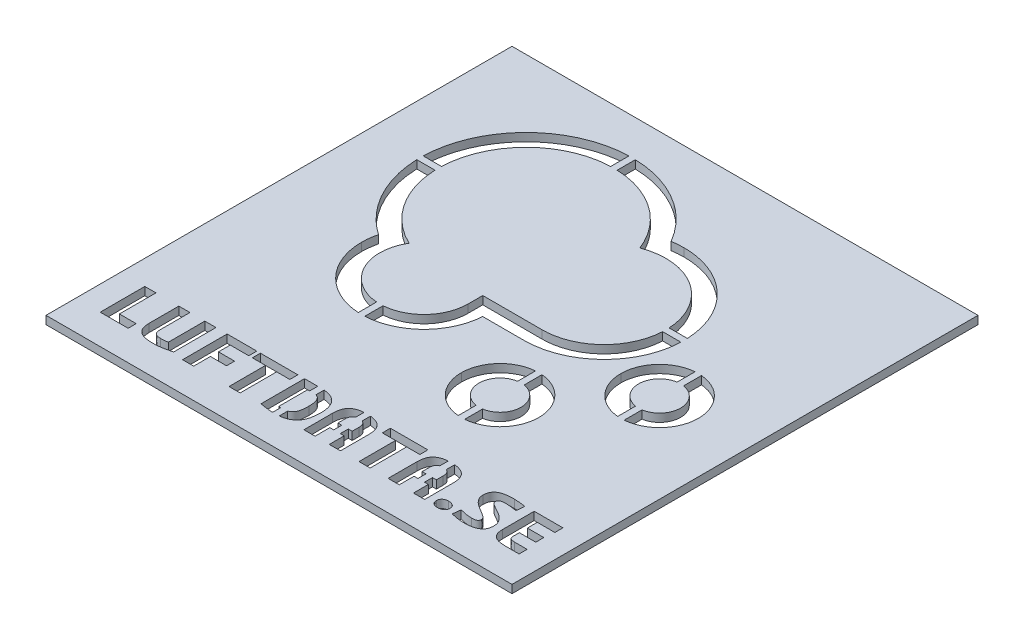
from build123d import *

# Parameters (mm, degrees)
BOSS_EXTRUDE2_DEPTH   = 2
SKETCH4_W             = 115
SKETCH4_H             = 115
BOSS_EXTRUDE2_2_DEPTH = 2
BOSS_EXTRUDE2_3_DEPTH = 2
BOSS_EXTRUDE2_4_DEPTH = 2
CUT_EXTRUDE1_DEPTH    = 2
SKETCH6_W             = 1.6
SKETCH6_H             = 9.016392518
SKETCH6_W_2           = 12.548523478
SKETCH6_H_2           = 1.6
SKETCH6_W_3           = 7.900848197
SKETCH6_H_3           = 10.834577131
SKETCH6_H_4           = 23.73823121
SKETCH6_H_5           = 23.744170643
SKETCH6_H_6           = 4.728687102
SKETCH6_H_7           = 7.537538453
SKETCH6_H_8           = 10.871158563
BOSS_EXTRUDE3_DEPTH   = 2


with BuildPart() as part:
    # Sketch4 → Boss-Extrude2 (new body)
    with BuildSketch(Plane(origin=(0, 0, 0), x_dir=(1, 0, 0), z_dir=(0, 1, 0))):
        with BuildLine():
            Line((-7.842765972, -9.564784729), (-7.842765972, -13.155399048))
            add(Edge.make_bspline(
                [(-7.842765972, -13.155399048), (-7.842935541, -19.185382566), (-12.733091514, -24.0752597), (-18.763092198, -24.075090131)],
                knots=[6, 6, 6, 6, 7, 7, 7, 7], degree=3))
            add(Edge.make_bspline(
                [(-18.763092198, -24.075090131), (-24.793092882, -24.074920559), (-29.682935683, -19.1847684), (-29.682766111, -13.154784881)],
                knots=[7, 7, 7, 7, 8, 8, 8, 8], degree=3))
            add(Edge.make_bspline(
                [(-29.682766111, -13.154784881), (-29.682766111, -11.079765045), (-29.102785261, -9.139766418), (-28.09776512, -7.489764892)],
                knots=[8, 8, 8, 8, 9, 9, 9, 9], degree=3))
            add(Edge.make_bspline(
                [(-28.09776512, -7.489764892), (-35.447785528, -4.019767486), (-40.527766378, 3.460212982), (-40.527766378, 12.125213898)],
                knots=[9, 9, 9, 9, 10, 10, 10, 10], degree=3))
            add(Edge.make_bspline(
                [(-40.527766378, 12.125213898), (-40.527766378, 24.100233353), (-30.81776634, 33.810213364), (-18.837766798, 33.810213364)],
                knots=[10, 10, 10, 10, 11, 11, 11, 11], degree=3))
            add(Edge.make_bspline(
                [(-18.837766798, 33.810213364), (-9.632766874, 33.810213364), (-1.767746122, 28.070232666), (1.377235262, 19.980232514)],
                knots=[0, 0, 0, 0, 1, 1, 1, 1], degree=3))
            add(Edge.make_bspline(
                [(1.377235262, 19.980232514), (3.067233889, 20.625213898), (4.902232973, 20.980232514), (6.822234957, 20.980232514)],
                knots=[1, 1, 1, 1, 2, 2, 2, 2], degree=3))
            add(Edge.make_bspline(
                [(6.822234957, 20.980232514), (15.257232515, 20.980232514), (22.0922316, 14.145214356), (22.0922316, 5.710212982)],
                knots=[2, 2, 2, 2, 3, 3, 3, 3], degree=3))
            add(Edge.make_bspline(
                [(22.0922316, 5.710212982), (22.0922316, -2.724784576), (15.257232515, -9.564784729), (6.822234957, -9.564784729)],
                knots=[3, 3, 3, 3, 4, 4, 4, 4], degree=3))
            Line((6.822234957, -9.564784729), (-7.842765972, -9.564784729))
        make_face()
    extrude(amount=BOSS_EXTRUDE2_DEPTH)



with BuildPart() as body_2:
    # Sketch4 → Boss-Extrude2 2 (new body)
    with BuildSketch(Plane(origin=(0, 0, 0), x_dir=(1, 0, 0), z_dir=(0, 1, 0))):
        with Locations((0, -10.190399849)):
            Rectangle(SKETCH4_W, SKETCH4_H)
        with BuildLine():
            Line((-3.369278118, -14.064975464), (6.822040394, -14.06540271))
            add(Edge.make_bspline(
                [(6.822040394, -14.06540271), (17.723441914, -14.06540271), (26.592231587, -5.194381439), (26.592231587, 5.709598816)],
                knots=[6, 6, 6, 6, 7, 7, 7, 7], degree=3))
            add(Edge.make_bspline(
                [(26.592231587, 5.709598816), (26.592231587, 16.610832489), (17.723441914, 25.479618347), (6.822234944, 25.479618347)],
                knots=[7, 7, 7, 7, 8, 8, 8, 8], degree=3))
            add(Edge.make_bspline(
                [(6.822234944, 25.479618347), (5.811405018, 25.479618347), (4.809924916, 25.403877533), (3.82228835, 25.253231323)],
                knots=[8, 8, 8, 8, 9, 9, 9, 9], degree=3))
            add(Edge.make_bspline(
                [(3.82228835, 25.253231323), (1.910270527, 28.555517471), (-0.706497356, 31.405149735), (-3.884784862, 33.620214737)],
                knots=[9, 9, 9, 9, 10, 10, 10, 10], degree=3))
            add(Edge.make_bspline(
                [(-3.884784862, 33.620214737), (-8.286651775, 36.688041962), (-13.457325145, 38.309600151), (-18.837766811, 38.309600151)],
                knots=[10, 10, 10, 10, 11, 11, 11, 11], degree=3))
            add(Edge.make_bspline(
                [(-18.837766811, 38.309600151), (-33.278976604, 38.309600151), (-45.027765915, 26.563061035), (-45.027765915, 12.124599732)],
                knots=[0, 0, 0, 0, 1, 1, 1, 1], degree=3))
            add(Edge.make_bspline(
                [(-45.027765915, 12.124599732), (-45.027765915, 3.483356751), (-40.700526401, -4.580489838), (-33.724340602, -9.419315063)],
                knots=[1, 1, 1, 1, 2, 2, 2, 2], degree=3))
            add(Edge.make_bspline(
                [(-33.724340602, -9.419315063), (-34.027487918, -10.634566986), (-34.182766124, -11.888732635), (-34.182766124, -13.155399048)],
                knots=[2, 2, 2, 2, 3, 3, 3, 3], degree=3))
            add(Edge.make_bspline(
                [(-34.182766124, -13.155399048), (-34.182766124, -21.65801593), (-27.265400096, -28.575397217), (-18.762785122, -28.575397217)],
                knots=[3, 3, 3, 3, 4, 4, 4, 4], degree=3))
            add(Edge.make_bspline(
                [(-18.762785122, -28.575397217), (-10.565300151, -28.575397217), (-3.841350719, -22.146121704), (-3.369278118, -14.064975464)],
                knots=[4, 4, 4, 4, 5, 5, 5, 5], degree=3))
        make_face(mode=Mode.SUBTRACT)
        with BuildLine():
            add(Edge.make_bspline(
                [(15.583556965, -38.288196289), (20.8599623, -38.288196289), (25.152625874, -33.995532715), (25.152625874, -28.71912738)],
                knots=[2, 2, 2, 2, 3, 3, 3, 3], degree=3))
            add(Edge.make_bspline(
                [(25.152625874, -28.71912738), (25.152625874, -23.442722046), (20.8599623, -19.150058472), (15.583556965, -19.150058472)],
                knots=[3, 3, 3, 3, 4, 4, 4, 4], degree=3))
            add(Edge.make_bspline(
                [(15.583556965, -19.150058472), (10.307151631, -19.150058472), (6.014484242, -23.442722046), (6.014484242, -28.71912738)],
                knots=[0, 0, 0, 0, 1, 1, 1, 1], degree=3))
            add(Edge.make_bspline(
                [(6.014484242, -28.71912738), (6.014484242, -33.995532715), (10.307151631, -38.288196289), (15.583556965, -38.288196289)],
                knots=[1, 1, 1, 1, 2, 2, 2, 2], degree=3))
        make_face(mode=Mode.SUBTRACT)
        with BuildLine():
            add(Edge.make_bspline(
                [(25.878173664, -9.214587891), (25.878173664, -14.490993225), (30.170837239, -18.783656799), (35.447242573, -18.783656799)],
                knots=[1, 1, 1, 1, 2, 2, 2, 2], degree=3))
            add(Edge.make_bspline(
                [(35.447242573, -18.783656799), (40.723647908, -18.783656799), (45.016311482, -14.490993225), (45.016311482, -9.214587891)],
                knots=[2, 2, 2, 2, 3, 3, 3, 3], degree=3))
            add(Edge.make_bspline(
                [(45.016311482, -9.214587891), (45.016311482, -3.938182556), (40.723647908, 0.354484833), (35.447242573, 0.354484833)],
                knots=[3, 3, 3, 3, 4, 4, 4, 4], degree=3))
            add(Edge.make_bspline(
                [(35.447242573, 0.354484833), (30.170837239, 0.354484833), (25.878173664, -3.938182556), (25.878173664, -9.214587891)],
                knots=[0, 0, 0, 0, 1, 1, 1, 1], degree=3))
        make_face(mode=Mode.SUBTRACT)
    extrude(amount=BOSS_EXTRUDE2_2_DEPTH)

    # Sketch5 → Cut-Extrude1 (cut)
    with BuildSketch(Plane(origin=(0, 2, 0), x_dir=(1, 0, 0), z_dir=(0, 1, 0))):
        Polygon((-48.736111111, -49.324270548), (-48.736111111, -58.338159437), (-44.596788194, -58.338159437), (-44.596788194, -60.324270548), (-51.486111111, -60.324270548), (-51.486111111, -49.324270548), align=None)
        with BuildLine():
            Line((-40.333333333, -49.324270548), (-40.333333333, -56.829478882))
            add(Edge.make_bspline(
                [(-40.333333333, -56.829478882), (-40.332200977, -56.901954107), (-40.330004209, -57.042555839), (-40.306334383, -57.24486519), (-40.265828949, -57.431316944), (-40.208694537, -57.600985762), (-40.136894589, -57.754871215), (-40.051036252, -57.894039132), (-39.944638781, -58.013299399), (-39.781676238, -58.153189332), (-39.537640923, -58.291214896), (-39.20267844, -58.407016163), (-38.820542279, -58.47945449), (-38.54968104, -58.486973627), (-38.406901042, -58.490937215)],
                knots=[0, 0, 0, 0, 0.000217349, 0.000421656, 0.000609894, 0.000788803, 0.000957532, 0.001118466, 0.001277458, 0.001434884, 0.001761191, 0.002110768, 0.002494677, 0.002922644, 0.002922644, 0.002922644, 0.002922644], degree=3))
            add(Edge.make_bspline(
                [(-38.406901042, -58.490937215), (-38.234910048, -58.488562504), (-37.901500571, -58.483959059), (-37.495054706, -58.445216927), (-37.194574803, -58.407311829), (-36.996668209, -58.375393851), (-36.822554688, -58.346421383), (-36.715895929, -58.321169039), (-36.666666667, -58.309513604)],
                knots=[0, 0, 0, 0, 0.000515824, 0.000999939, 0.001223785, 0.001424334, 0.001601338, 0.001753068, 0.001753068, 0.001753068, 0.001753068], degree=3))
            Line((-36.666666667, -58.309513604), (-36.666666667, -49.324270548))
            Line((-36.666666667, -49.324270548), (-33.916666667, -49.324270548))
            Line((-33.916666667, -49.324270548), (-33.916666667, -59.787161173))
            add(Edge.make_bspline(
                [(-33.916666667, -59.787161173), (-34.053462569, -59.820860516), (-34.34337453, -59.892279633), (-34.804934109, -59.999657248), (-35.31769973, -60.112837333), (-35.876593073, -60.237760177), (-36.480126182, -60.34689785), (-37.122797066, -60.420233918), (-37.799754158, -60.470798457), (-38.262776498, -60.474931047), (-38.5, -60.477048326)],
                knots=[0, 0, 0, 0, 0.000422654, 0.000895732, 0.001421605, 0.001997978, 0.002613757, 0.003260428, 0.003937678, 0.004649193, 0.004649193, 0.004649193, 0.004649193], degree=3))
            add(Edge.make_bspline(
                [(-38.5, -60.477048326), (-38.704603977, -60.473955911), (-39.097696887, -60.468014645), (-39.662229196, -60.419939399), (-40.177444367, -60.343764142), (-40.644134684, -60.231906682), (-41.063698281, -60.087757385), (-41.442774457, -59.920256672), (-41.776264293, -59.717525025), (-42.072446126, -59.490527761), (-42.324049233, -59.229775098), (-42.539779912, -58.942297119), (-42.71708302, -58.625196891), (-42.855307012, -58.278872035), (-42.956673922, -57.905038164), (-43.029202129, -57.507298334), (-43.076526227, -57.083649374), (-43.081018881, -56.79300857), (-43.083333333, -56.643280965)],
                knots=[0, 0, 0, 0, 0.000613726, 0.001179113, 0.001698361, 0.002174866, 0.002616489, 0.003027815, 0.003415512, 0.003784626, 0.0041442, 0.004498931, 0.004860173, 0.005230759, 0.005614742, 0.006020207, 0.006442787, 0.0068918, 0.0068918, 0.0068918, 0.0068918], degree=3))
            Line((-43.083333333, -56.643280965), (-43.083333333, -49.324270548))
            Line((-43.083333333, -49.324270548), (-40.333333333, -49.324270548))
        make_face()
        Polygon((-23.84765625, -49.324270548), (-23.84765625, -51.310381659), (-28.416666667, -51.310381659), (-28.416666667, -54.213159437), (-24.442057292, -54.213159437), (-24.442057292, -56.199270548), (-28.416666667, -56.199270548), (-28.416666667, -60.324270548), (-31.166666667, -60.324270548), (-31.166666667, -49.324270548), align=None)
        Polygon((-13.70703125, -49.324270548), (-13.70703125, -51.310381659), (-16.958333333, -51.310381659), (-16.958333333, -60.324270548), (-19.708333333, -60.324270548), (-19.708333333, -51.310381659), (-22.959635417, -51.310381659), (-22.959635417, -49.324270548), align=None)
        with BuildLine():
            add(Edge.make_bspline(
                [(-7.810763889, -49.324270548), (-7.616439653, -49.327494746), (-7.237960983, -49.333774405), (-6.686516865, -49.395326798), (-6.166635512, -49.492113977), (-5.677692546, -49.627197613), (-5.222562951, -49.803087443), (-4.802993051, -50.02136097), (-4.421402923, -50.282638114), (-4.076801645, -50.586493344), (-3.769035645, -50.931693166), (-3.502181094, -51.324067704), (-3.273054427, -51.76070477), (-3.082211227, -52.243204719), (-2.931723738, -52.771641728), (-2.826515289, -53.346364091), (-2.761067041, -53.968155462), (-2.75377775, -54.398389413), (-2.75, -54.621362562)],
                knots=[0, 0, 0, 0, 0.000582778, 0.001135057, 0.001662234, 0.002167866, 0.002654611, 0.003123351, 0.003583533, 0.004038503, 0.004498425, 0.004967214, 0.005458411, 0.005974836, 0.006521119, 0.007104019, 0.007725642, 0.00839439, 0.00839439, 0.00839439, 0.00839439], degree=3))
            add(Edge.make_bspline(
                [(-2.75, -54.621362562), (-2.752449539, -54.823566227), (-2.75727787, -55.222133406), (-2.804440622, -55.809351256), (-2.877400815, -56.376150211), (-2.980118333, -56.920360595), (-3.121802486, -57.437695281), (-3.308737387, -57.924429932), (-3.553364647, -58.372465437), (-3.79269579, -58.719589011), (-4.008233266, -58.978579734), (-4.187820292, -59.159843951), (-4.383215095, -59.329317482), (-4.59009013, -59.493004288), (-4.8150399, -59.642647473), (-5.054772165, -59.781076793), (-5.308886375, -59.910280552), (-5.578151454, -60.030559941), (-5.866604895, -60.134703), (-6.171863439, -60.229261586), (-6.498717078, -60.303628977), (-6.84392987, -60.369559287), (-7.210105541, -60.415043524), (-7.594520649, -60.451568231), (-7.999103053, -60.473142028), (-8.275437723, -60.475724448), (-8.417100694, -60.477048326)],
                knots=[0, 0, 0, 0, 0.000606506, 0.001195494, 0.001766069, 0.002320382, 0.00285553, 0.0033733, 0.003880648, 0.00438325, 0.004635713, 0.004890602, 0.005147729, 0.005411323, 0.005681451, 0.005957412, 0.006241393, 0.006536368, 0.006841476, 0.0071609, 0.007494419, 0.007846505, 0.008214847, 0.008600843, 0.009004844, 0.009429817, 0.009429817, 0.009429817, 0.009429817], degree=3))
            add(Edge.make_bspline(
                [(-8.417100694, -60.477048326), (-8.550791557, -60.475210334), (-8.822242865, -60.471478402), (-9.23708967, -60.455387503), (-9.66601176, -60.423180478), (-10.111078656, -60.380715809), (-10.57272804, -60.323018984), (-11.05308391, -60.249924246), (-11.555087077, -60.168181913), (-11.895365254, -60.100885489), (-12.069444444, -60.066458048)],
                knots=[0, 0, 0, 0, 0.000401106, 0.000814421, 0.001245228, 0.001691312, 0.002155581, 0.002640714, 0.003148931, 0.003681245, 0.003681245, 0.003681245, 0.003681245], degree=3))
            Line((-12.069444444, -60.066458048), (-12.069444444, -49.324270548))
            Line((-12.069444444, -49.324270548), (-7.810763889, -49.324270548))
        make_face()
        with BuildLine():
            add(Edge.make_bspline(
                [(-9.319444444, -58.42648409), (-9.233513592, -58.435273006), (-9.069683333, -58.452029391), (-8.830444909, -58.475914253), (-8.599439284, -58.487584309), (-8.446552552, -58.489812278), (-8.369357639, -58.490937215)],
                knots=[0, 0, 0, 0, 0.000259146, 0.000494072, 0.000721165, 0.000952768, 0.000952768, 0.000952768, 0.000952768], degree=3))
            add(Edge.make_bspline(
                [(-8.369357639, -58.490937215), (-8.239484105, -58.488862651), (-7.989908172, -58.484875994), (-7.634909781, -58.436292037), (-7.314874762, -58.36113301), (-7.029843123, -58.2542269), (-6.777843599, -58.113004116), (-6.553677468, -57.944573004), (-6.354884485, -57.747455725), (-6.188029666, -57.516749974), (-6.043971251, -57.260627844), (-5.928044131, -56.975161374), (-5.831720616, -56.664869744), (-5.764312757, -56.324504796), (-5.716887354, -55.957358984), (-5.677093991, -55.561846058), (-5.656891367, -55.137997178), (-5.654175587, -54.845772195), (-5.652777778, -54.695364298)],
                knots=[0, 0, 0, 0, 0.000389369, 0.000748245, 0.001072476, 0.001373948, 0.00165821, 0.001936075, 0.002212902, 0.002494597, 0.002787439, 0.003092444, 0.003417132, 0.003760766, 0.004131789, 0.004527517, 0.004952973, 0.005404202, 0.005404202, 0.005404202, 0.005404202], degree=3))
            add(Edge.make_bspline(
                [(-5.652777778, -54.695364298), (-5.654672128, -54.543345715), (-5.658295287, -54.252592957), (-5.683843936, -53.834994773), (-5.728554216, -53.455586223), (-5.790374393, -53.111897634), (-5.867687146, -52.801446588), (-5.966640489, -52.52321935), (-6.078565707, -52.273099292), (-6.214576404, -52.056891504), (-6.362560929, -51.867755796), (-6.528752915, -51.708347195), (-6.711464791, -51.578209519), (-6.910780906, -51.477251104), (-7.124207135, -51.400523708), (-7.353755725, -51.349712251), (-7.597986463, -51.314030409), (-7.766859911, -51.311621079), (-7.853732639, -51.310381659)],
                knots=[0, 0, 0, 0, 0.000456046, 0.00087224, 0.001254498, 0.001601457, 0.001919316, 0.002213013, 0.002486444, 0.002739482, 0.002977337, 0.003205269, 0.003427825, 0.003647755, 0.003873527, 0.004106308, 0.00435208, 0.004612455, 0.004612455, 0.004612455, 0.004612455], degree=3))
            Line((-7.853732639, -51.310381659), (-9.319444444, -51.310381659))
            Line((-9.319444444, -51.310381659), (-9.319444444, -58.42648409))
        make_face(mode=Mode.SUBTRACT)
        with BuildLine():
            Line((1.527777778, -60.324270548), (-1.222222222, -60.324270548))
            Line((-1.222222222, -60.324270548), (-1.222222222, -53.208168118))
            add(Edge.make_bspline(
                [(-1.222222222, -53.208168118), (-1.219399837, -53.057687821), (-1.213878864, -52.763327694), (-1.172942712, -52.333369191), (-1.105732564, -51.9250921), (-1.0154423, -51.537965851), (-0.889067157, -51.174359767), (-0.724785951, -50.838114836), (-0.518692251, -50.531767835), (-0.276155897, -50.25216437), (0.00799921, -50.002512819), (0.333813981, -49.78383426), (0.702189353, -49.597743952), (1.114413947, -49.442673563), (1.574405979, -49.317666876), (2.086893097, -49.232204698), (2.651808401, -49.179430509), (3.045880418, -49.174212705), (3.251302083, -49.171492771)],
                knots=[0, 0, 0, 0, 0.000451399, 0.000882999, 0.001294282, 0.00169205, 0.002074069, 0.002446656, 0.002811461, 0.003178625, 0.003554099, 0.003942743, 0.004352702, 0.0047894, 0.005261942, 0.005780372, 0.006346183, 0.006962295, 0.006962295, 0.006962295, 0.006962295], degree=3))
            add(Edge.make_bspline(
                [(3.251302083, -49.171492771), (3.45751462, -49.174237437), (3.853165636, -49.179503509), (4.41973469, -49.231904143), (4.934399775, -49.318314947), (5.397651823, -49.442671586), (5.814652956, -49.597730636), (6.187606553, -49.783954382), (6.518212754, -50.001632975), (6.804843081, -50.252908631), (7.052402423, -50.531407797), (7.262750491, -50.83847073), (7.43467338, -51.173872256), (7.568253617, -51.53760162), (7.665402019, -51.924858539), (7.741256014, -52.332786857), (7.783610237, -52.763256657), (7.788941815, -53.05768984), (7.791666667, -53.208168118)],
                knots=[0, 0, 0, 0, 0.000618498, 0.001186686, 0.001705116, 0.002182266, 0.002623431, 0.003037648, 0.00343026, 0.003807529, 0.004177845, 0.004545327, 0.004921135, 0.005305585, 0.00570509, 0.006117598, 0.006549428, 0.007000827, 0.007000827, 0.007000827, 0.007000827], degree=3))
            Line((7.791666667, -53.208168118), (7.791666667, -60.324270548))
            Line((7.791666667, -60.324270548), (5.041666667, -60.324270548))
            Line((5.041666667, -60.324270548), (5.041666667, -56.657603882))
            Line((5.041666667, -56.657603882), (1.527777778, -56.657603882))
            Line((1.527777778, -56.657603882), (1.527777778, -60.324270548))
        make_face()
        with BuildLine():
            Line((5.041666667, -54.671492771), (5.041666667, -52.979001451))
            add(Edge.make_bspline(
                [(5.041666667, -52.979001451), (5.040147678, -52.906556121), (5.037204359, -52.766179933), (5.018625594, -52.561758969), (4.98489977, -52.371205828), (4.940633787, -52.193322277), (4.880374726, -52.029381011), (4.806562038, -51.879054672), (4.720316376, -51.742085898), (4.622013709, -51.618455269), (4.507606448, -51.509939047), (4.378991719, -51.413006636), (4.231498643, -51.336577954), (4.073132073, -51.26705817), (3.896925255, -51.218435572), (3.706042175, -51.183086911), (3.50005971, -51.161389), (3.357981511, -51.158891605), (3.284722222, -51.157603882)],
                knots=[0, 0, 0, 0, 0.000217349, 0.000421154, 0.000615028, 0.000797407, 0.000970356, 0.001137968, 0.001298902, 0.00145511, 0.00161044, 0.001770859, 0.001936418, 0.002107562, 0.002288892, 0.002483192, 0.002689608, 0.002909343, 0.002909343, 0.002909343, 0.002909343], degree=3))
            add(Edge.make_bspline(
                [(3.284722222, -51.157603882), (3.211462933, -51.158891605), (3.069384734, -51.161389), (2.863402269, -51.183086911), (2.672519189, -51.218435572), (2.496312371, -51.26705817), (2.337945801, -51.336577954), (2.190452726, -51.413006636), (2.061837997, -51.509939047), (1.947430735, -51.618455269), (1.849128069, -51.742085898), (1.762882406, -51.879054672), (1.689069719, -52.029381011), (1.628810657, -52.193322277), (1.584544675, -52.371205828), (1.55081885, -52.561758969), (1.532240086, -52.766179933), (1.529296766, -52.906556121), (1.527777778, -52.979001451)],
                knots=[0, 0, 0, 0, 0.000219735, 0.000426151, 0.000620451, 0.000801781, 0.000972925, 0.001138484, 0.001298903, 0.001454233, 0.001610441, 0.001771375, 0.001938987, 0.002111936, 0.002294315, 0.002488189, 0.002691994, 0.002909343, 0.002909343, 0.002909343, 0.002909343], degree=3))
            Line((1.527777778, -52.979001451), (1.527777778, -54.671492771))
            Line((1.527777778, -54.671492771), (5.041666667, -54.671492771))
        make_face(mode=Mode.SUBTRACT)
        Polygon((18.376302083, -49.324270548), (18.376302083, -51.310381659), (15.125, -51.310381659), (15.125, -60.324270548), (12.375, -60.324270548), (12.375, -51.310381659), (9.123697917, -51.310381659), (9.123697917, -49.324270548), align=None)
        with BuildLine():
            Line((22.305555556, -60.324270548), (19.555555556, -60.324270548))
            Line((19.555555556, -60.324270548), (19.555555556, -53.208168118))
            add(Edge.make_bspline(
                [(19.555555556, -53.208168118), (19.558377941, -53.057687821), (19.563898914, -52.763327694), (19.604835066, -52.333369191), (19.672045214, -51.9250921), (19.762335478, -51.537965851), (19.888710621, -51.174359767), (20.052991826, -50.838114836), (20.259085527, -50.531767835), (20.501621881, -50.25216437), (20.785776988, -50.002512819), (21.111591759, -49.78383426), (21.479967131, -49.597743952), (21.892191724, -49.442673563), (22.352183757, -49.317666876), (22.864670875, -49.232204698), (23.429586179, -49.179430509), (23.823658196, -49.174212705), (24.029079861, -49.171492771)],
                knots=[0, 0, 0, 0, 0.000451399, 0.000882999, 0.001294282, 0.00169205, 0.002074069, 0.002446656, 0.002811461, 0.003178625, 0.003554099, 0.003942743, 0.004352702, 0.0047894, 0.005261942, 0.005780372, 0.006346183, 0.006962295, 0.006962295, 0.006962295, 0.006962295], degree=3))
            add(Edge.make_bspline(
                [(24.029079861, -49.171492771), (24.235292398, -49.174237437), (24.630943414, -49.179503509), (25.197512468, -49.231904143), (25.712177553, -49.318314947), (26.175429601, -49.442671586), (26.592430734, -49.597730636), (26.965384331, -49.783954382), (27.295990532, -50.001632975), (27.582620858, -50.252908631), (27.830180201, -50.531407797), (28.040528269, -50.83847073), (28.212451158, -51.173872256), (28.346031395, -51.53760162), (28.443179797, -51.924858539), (28.519033792, -52.332786857), (28.561388015, -52.763256657), (28.566719593, -53.05768984), (28.569444444, -53.208168118)],
                knots=[0, 0, 0, 0, 0.000618498, 0.001186686, 0.001705116, 0.002182266, 0.002623431, 0.003037648, 0.00343026, 0.003807529, 0.004177845, 0.004545327, 0.004921135, 0.005305585, 0.00570509, 0.006117598, 0.006549428, 0.007000827, 0.007000827, 0.007000827, 0.007000827], degree=3))
            Line((28.569444444, -53.208168118), (28.569444444, -60.324270548))
            Line((28.569444444, -60.324270548), (25.819444444, -60.324270548))
            Line((25.819444444, -60.324270548), (25.819444444, -56.657603882))
            Line((25.819444444, -56.657603882), (22.305555556, -56.657603882))
            Line((22.305555556, -56.657603882), (22.305555556, -60.324270548))
        make_face()
        with BuildLine():
            Line((25.819444444, -54.671492771), (25.819444444, -52.979001451))
            add(Edge.make_bspline(
                [(25.819444444, -52.979001451), (25.817925456, -52.906556121), (25.814982136, -52.766179933), (25.796403372, -52.561758969), (25.762677548, -52.371205828), (25.718411565, -52.193322277), (25.658152503, -52.029381011), (25.584339816, -51.879054672), (25.498094154, -51.742085898), (25.399791487, -51.618455269), (25.285384225, -51.509939047), (25.156769496, -51.413006636), (25.009276421, -51.336577954), (24.850909851, -51.26705817), (24.674703033, -51.218435572), (24.483819953, -51.183086911), (24.277837488, -51.161389), (24.135759289, -51.158891605), (24.0625, -51.157603882)],
                knots=[0, 0, 0, 0, 0.000217349, 0.000421154, 0.000615028, 0.000797407, 0.000970356, 0.001137968, 0.001298902, 0.00145511, 0.00161044, 0.001770859, 0.001936418, 0.002107562, 0.002288892, 0.002483192, 0.002689608, 0.002909343, 0.002909343, 0.002909343, 0.002909343], degree=3))
            add(Edge.make_bspline(
                [(24.0625, -51.157603882), (23.989240711, -51.158891605), (23.847162512, -51.161389), (23.641180047, -51.183086911), (23.450296967, -51.218435572), (23.274090149, -51.26705817), (23.115723579, -51.336577954), (22.968230504, -51.413006636), (22.839615775, -51.509939047), (22.725208513, -51.618455269), (22.626905846, -51.742085898), (22.540660184, -51.879054672), (22.466847497, -52.029381011), (22.406588435, -52.193322277), (22.362322452, -52.371205828), (22.328596628, -52.561758969), (22.310017864, -52.766179933), (22.307074544, -52.906556121), (22.305555556, -52.979001451)],
                knots=[0, 0, 0, 0, 0.000219735, 0.000426151, 0.000620451, 0.000801781, 0.000972925, 0.001138484, 0.001298903, 0.001454233, 0.001610441, 0.001771375, 0.001938987, 0.002111936, 0.002294315, 0.002488189, 0.002691994, 0.002909343, 0.002909343, 0.002909343, 0.002909343], degree=3))
            Line((22.305555556, -52.979001451), (22.305555556, -54.671492771))
            Line((22.305555556, -54.671492771), (25.819444444, -54.671492771))
        make_face(mode=Mode.SUBTRACT)
        with BuildLine():
            add(Edge.make_bspline(
                [(31.923394097, -57.727048326), (32.047092543, -57.730443448), (32.282196934, -57.736896302), (32.615068479, -57.804958497), (32.908742467, -57.915360185), (33.158118604, -58.075609968), (33.364481453, -58.273412007), (33.508333314, -58.519780826), (33.596689435, -58.802499491), (33.606177745, -59.004290343), (33.611111111, -59.109209784)],
                knots=[0, 0, 0, 0, 0.000370632, 0.000704432, 0.001014303, 0.001306327, 0.001588223, 0.001863337, 0.002153275, 0.002467301, 0.002467301, 0.002467301, 0.002467301], degree=3))
            add(Edge.make_bspline(
                [(33.611111111, -59.109209784), (33.606315836, -59.212590007), (33.597130984, -59.410604111), (33.507279963, -59.688114852), (33.363804008, -59.931062402), (33.158095118, -60.128302903), (32.909285123, -60.28947489), (32.614169959, -60.395303917), (32.282631421, -60.468305859), (32.04718635, -60.474035695), (31.923394097, -60.477048326)],
                knots=[0, 0, 0, 0, 0.000309272, 0.000592379, 0.000865445, 0.001147341, 0.001439365, 0.001748379, 0.002082666, 0.002453298, 0.002453298, 0.002453298, 0.002453298], degree=3))
            add(Edge.make_bspline(
                [(31.923394097, -60.477048326), (31.802027253, -60.473873282), (31.569821802, -60.46779862), (31.242522027, -60.396114742), (30.950522861, -60.287405464), (30.700855662, -60.130018577), (30.497466039, -59.930066379), (30.353708257, -59.688253202), (30.264014689, -59.410565201), (30.25480713, -59.21257666), (30.25, -59.109209784)],
                knots=[0, 0, 0, 0, 0.000363483, 0.000695434, 0.00099999, 0.001294027, 0.001574231, 0.001847296, 0.002130403, 0.002439675, 0.002439675, 0.002439675, 0.002439675], degree=3))
            add(Edge.make_bspline(
                [(30.25, -59.109209784), (30.254945502, -59.004304014), (30.264457153, -58.802539457), (30.352651228, -58.519638239), (30.496794352, -58.274413978), (30.700830978, -58.07389268), (30.951081074, -57.917445095), (31.241613226, -57.804155311), (31.570256725, -57.737388469), (31.802120471, -57.730599314), (31.923394097, -57.727048326)],
                knots=[0, 0, 0, 0, 0.000314026, 0.000603965, 0.000879078, 0.001159282, 0.001453318, 0.001758743, 0.002090205, 0.002453688, 0.002453688, 0.002453688, 0.002453688], degree=3))
        make_face()
        with BuildLine():
            add(Edge.make_bspline(
                [(42.223958333, -51.436900757), (42.125312142, -51.420846266), (41.917035279, -51.386949579), (41.591768077, -51.337012856), (41.245568304, -51.29020342), (40.889944796, -51.247047545), (40.533349551, -51.211617971), (40.184818316, -51.183224521), (39.852954161, -51.162642683), (39.638698662, -51.15923628), (39.536024306, -51.157603882)],
                knots=[0, 0, 0, 0, 0.000299832, 0.000633052, 0.000987196, 0.001347838, 0.001707697, 0.002062155, 0.002396902, 0.002704928, 0.002704928, 0.002704928, 0.002704928], degree=3))
            add(Edge.make_bspline(
                [(39.536024306, -51.157603882), (39.396662876, -51.15944211), (39.135717731, -51.162884071), (38.771176569, -51.199305091), (38.458718973, -51.252216027), (38.234366822, -51.323724831), (38.082782578, -51.394113895), (37.990345448, -51.460927371), (37.91099225, -51.536335965), (37.847135238, -51.625756992), (37.797521587, -51.725747141), (37.761422257, -51.837505473), (37.739796068, -51.960442882), (37.737371588, -52.046328854), (37.736111111, -52.090980618)],
                knots=[0, 0, 0, 0, 0.000417922, 0.000782532, 0.001098106, 0.001366849, 0.001486421, 0.001597699, 0.001707431, 0.001813437, 0.001925532, 0.002041032, 0.002164658, 0.00229853, 0.00229853, 0.00229853, 0.00229853], degree=3))
            add(Edge.make_bspline(
                [(37.736111111, -52.090980618), (37.74093178, -52.148188954), (37.750722701, -52.264380797), (37.826765044, -52.432366578), (37.94683072, -52.591168041), (38.113043143, -52.739196679), (38.31076889, -52.88419074), (38.533457044, -53.031193318), (38.777143481, -53.183536405), (39.146333192, -53.384390459), (39.642382804, -53.653570091), (40.157543146, -53.932777223), (40.57993334, -54.175609203), (40.889406864, -54.380451213), (41.187187494, -54.599789386), (41.473959347, -54.833047385), (41.744784611, -55.081555539), (41.989713258, -55.354182288), (42.211325248, -55.645732747), (42.412319257, -55.955394415), (42.577002548, -56.291289384), (42.694821202, -56.656665123), (42.764393378, -57.051221635), (42.773232605, -57.324130491), (42.777777778, -57.464461521)],
                knots=[0, 0, 0, 0, 0.000171161, 0.000347632, 0.000543859, 0.000765144, 0.001012454, 0.001279271, 0.00156546, 0.001874299, 0.002539771, 0.00325878, 0.003632169, 0.004000951, 0.004371453, 0.004741299, 0.005109525, 0.005472914, 0.005839114, 0.006207301, 0.006578839, 0.006957803, 0.007355369, 0.007776186, 0.007776186, 0.007776186, 0.007776186], degree=3))
            add(Edge.make_bspline(
                [(42.777777778, -57.464461521), (42.77492701, -57.591163248), (42.769396138, -57.836981658), (42.716617667, -58.192000618), (42.6275491, -58.520174649), (42.506621773, -58.822464833), (42.349470176, -59.099562734), (42.155199229, -59.348355316), (41.925557246, -59.570021974), (41.662265965, -59.764143735), (41.367076929, -59.933610708), (41.04062586, -60.077809037), (40.68517423, -60.203699416), (40.297653631, -60.300455729), (39.881546287, -60.384180765), (39.433629668, -60.435913974), (38.955694755, -60.470354463), (38.626586694, -60.47477228), (38.45703125, -60.477048326)],
                knots=[0, 0, 0, 0, 0.000379925, 0.000737106, 0.001073559, 0.001398045, 0.001711308, 0.002025987, 0.002341678, 0.002665857, 0.003004883, 0.003360697, 0.003735168, 0.004134672, 0.004557892, 0.005007653, 0.005486252, 0.005994856, 0.005994856, 0.005994856, 0.005994856], degree=3))
            add(Edge.make_bspline(
                [(38.45703125, -60.477048326), (38.282736494, -60.475231793), (37.943448307, -60.471695667), (37.449426241, -60.443899999), (36.984482164, -60.392867209), (36.548953048, -60.326702898), (36.142317581, -60.245967319), (35.76331563, -60.163763752), (35.409108757, -60.0871166), (35.183299649, -60.029690419), (35.074435764, -60.002004923)],
                knots=[0, 0, 0, 0, 0.000522874, 0.001017844, 0.001483657, 0.00192559, 0.002338981, 0.002727119, 0.003089094, 0.003426054, 0.003426054, 0.003426054, 0.003426054], degree=3))
            Line((35.074435764, -60.002004923), (35.303602431, -58.027829576))
            add(Edge.make_bspline(
                [(35.303602431, -58.027829576), (35.539674669, -58.086191279), (36.008012018, -58.201973488), (36.600028042, -58.331525105), (37.086711985, -58.417802155), (37.479943785, -58.45854888), (37.900446116, -58.48548355), (38.190419214, -58.489080828), (38.340060764, -58.490937215)],
                knots=[0, 0, 0, 0, 0.00072952, 0.001447276, 0.001817746, 0.00221159, 0.002632549, 0.003081435, 0.003081435, 0.003081435, 0.003081435], degree=3))
            add(Edge.make_bspline(
                [(38.340060764, -58.490937215), (38.441940996, -58.489629761), (38.640431695, -58.48708248), (38.928344657, -58.465518655), (39.192292713, -58.418184504), (39.42670735, -58.33904683), (39.620676294, -58.221208383), (39.745114323, -58.087934046), (39.811079719, -57.96248886), (39.850764823, -57.856273809), (39.871181112, -57.734978637), (39.873685819, -57.649928189), (39.875, -57.605303534)],
                knots=[0, 0, 0, 0, 0.000305639, 0.00059547, 0.000865144, 0.001108259, 0.001333462, 0.001539644, 0.001645382, 0.001757145, 0.001878421, 0.002012293, 0.002012293, 0.002012293, 0.002012293], degree=3))
            add(Edge.make_bspline(
                [(39.875, -57.605303534), (39.870187995, -57.540240544), (39.860469553, -57.408837747), (39.786064875, -57.217534718), (39.665681084, -57.036337476), (39.499240257, -56.86632934), (39.301754552, -56.69955825), (39.07800265, -56.533735278), (38.835279547, -56.361841089), (38.465879283, -56.139036468), (37.970982952, -55.845437191), (37.346755637, -55.489180339), (36.721255499, -55.098399448), (36.230605097, -54.727131162), (35.867017637, -54.407632197), (35.623625065, -54.14733465), (35.401184951, -53.87512074), (35.1996648, -53.589288373), (35.0347437, -53.27983866), (34.916890917, -52.943769459), (34.847004006, -52.583233849), (34.83795341, -52.334779916), (34.833333333, -52.207951104)],
                knots=[0, 0, 0, 0, 0.000194827, 0.000393478, 0.000607338, 0.000843751, 0.001104486, 0.001382351, 0.001679022, 0.001996333, 0.002675939, 0.003405533, 0.004152525, 0.004886826, 0.005248619, 0.005603238, 0.005954442, 0.006302745, 0.006650852, 0.00700268, 0.007367384, 0.007747691, 0.007747691, 0.007747691, 0.007747691], degree=3))
            add(Edge.make_bspline(
                [(34.833333333, -52.207951104), (34.837321301, -52.061313387), (34.844968011, -51.780143521), (34.90637615, -51.37889159), (35.010453878, -51.018274882), (35.160017288, -50.697804852), (35.352161739, -50.416688283), (35.575905533, -50.164162055), (35.838244244, -49.946724568), (36.136054787, -49.761237387), (36.467295416, -49.608965284), (36.826461634, -49.475559265), (37.217413215, -49.37549718), (37.636215328, -49.297082575), (38.082866323, -49.241519948), (38.555164506, -49.202276598), (39.05347834, -49.173923339), (39.394344076, -49.172317618), (39.569444444, -49.171492771)],
                knots=[0, 0, 0, 0, 0.000439761, 0.000843218, 0.001214088, 0.00156222, 0.001899223, 0.002232272, 0.002571231, 0.002917639, 0.00328178, 0.003663164, 0.004065582, 0.004490696, 0.004940755, 0.00541515, 0.005912372, 0.006437595, 0.006437595, 0.006437595, 0.006437595], degree=3))
            add(Edge.make_bspline(
                [(39.569444444, -49.171492771), (39.816295104, -49.175230831), (40.320481284, -49.182865725), (40.948544145, -49.246026719), (41.446926515, -49.305307647), (41.796879948, -49.353711619), (42.119547129, -49.399941801), (42.324298595, -49.435969327), (42.422092014, -49.453176798)],
                knots=[0, 0, 0, 0, 0.000740329, 0.001512103, 0.001891991, 0.002246135, 0.002571918, 0.002869787, 0.002869787, 0.002869787, 0.002869787], degree=3))
            Line((42.422092014, -49.453176798), (42.223958333, -51.436900757))
        make_face()
        with BuildLine():
            Line((51.700954861, -49.324270548), (51.700954861, -51.310381659))
            Line((51.700954861, -51.310381659), (47.361111111, -51.310381659))
            Line((47.361111111, -51.310381659), (47.361111111, -53.754826104))
            Line((47.361111111, -53.754826104), (51.421657986, -53.754826104))
            Line((51.421657986, -53.754826104), (51.421657986, -55.740937215))
            Line((51.421657986, -55.740937215), (47.361111111, -55.740937215))
            Line((47.361111111, -55.740937215), (47.361111111, -57.235294854))
            add(Edge.make_bspline(
                [(47.361111111, -57.235294854), (47.362528361, -57.289469183), (47.365247255, -57.393398849), (47.384586647, -57.542042412), (47.414501191, -57.67709082), (47.459788681, -57.797987771), (47.519524837, -57.902901525), (47.590635911, -57.994203828), (47.674062872, -58.072181647), (47.808318299, -58.150047166), (47.994631538, -58.224454626), (48.236132934, -58.292408999), (48.501847268, -58.329360278), (48.685875656, -58.335151339), (48.781467014, -58.338159437)],
                knots=[0, 0, 0, 0, 0.000162484, 0.000311715, 0.00044895, 0.000576635, 0.00069744, 0.000809661, 0.000922869, 0.001037502, 0.001272912, 0.001523108, 0.001788458, 0.002075274, 0.002075274, 0.002075274, 0.002075274], degree=3))
            Line((48.781467014, -58.338159437), (51.882378472, -58.338159437))
            Line((51.882378472, -58.338159437), (51.882378472, -60.324270548))
            Line((51.882378472, -60.324270548), (48.633463542, -60.324270548))
            add(Edge.make_bspline(
                [(48.633463542, -60.324270548), (48.475859991, -60.322618221), (48.169927084, -60.319410797), (47.724756311, -60.28951068), (47.307130113, -60.245497938), (46.917306595, -60.182982413), (46.556826417, -60.094981055), (46.224686701, -59.981592717), (45.923321829, -59.836803897), (45.647124593, -59.670793534), (45.404316885, -59.471336723), (45.194736025, -59.241027619), (45.013723427, -58.983456124), (44.864004467, -58.693274015), (44.749916461, -58.367781958), (44.670286477, -58.005511586), (44.619490982, -57.605940009), (44.613981831, -57.326172312), (44.611111111, -57.18039034)],
                knots=[0, 0, 0, 0, 0.000472753, 0.000917686, 0.001337893, 0.001732301, 0.002101106, 0.002449892, 0.002783035, 0.003102378, 0.003414448, 0.003721955, 0.004033879, 0.004356312, 0.004698342, 0.005065498, 0.005467292, 0.005904461, 0.005904461, 0.005904461, 0.005904461], degree=3))
            Line((44.611111111, -57.18039034), (44.611111111, -49.324270548))
            Line((44.611111111, -49.324270548), (51.700954861, -49.324270548))
        make_face()
    extrude(amount=-CUT_EXTRUDE1_DEPTH, mode=Mode.SUBTRACT)


with BuildPart() as body_3:
    # Sketch4 → Boss-Extrude2 3 (new body)
    with BuildSketch(Plane(origin=(0, 0, 0), x_dir=(1, 0, 0), z_dir=(0, 1, 0))):
        with BuildLine():
            add(Edge.make_bspline(
                [(15.583556965, -33.903529846), (12.720283345, -33.903529846), (10.399150685, -31.582401001), (10.399150685, -28.71912738), (10.399150685, -25.855869018), (12.720283345, -23.534724914), (15.583556965, -23.534724914)],
                knots=[2, 2, 2, 2, 3, 3, 3, 4, 4, 4, 4], degree=3))
            add(Edge.make_bspline(
                [(15.583556965, -23.534724914), (18.446830586, -23.534724914), (20.767959431, -25.855869018), (20.767959431, -28.71912738), (20.767959431, -31.582401001), (18.446830586, -33.903529846), (15.583556965, -33.903529846)],
                knots=[0, 0, 0, 0, 1, 1, 1, 2, 2, 2, 2], degree=3))
        make_face()
    extrude(amount=BOSS_EXTRUDE2_3_DEPTH)


with BuildPart() as body_4:
    # Sketch4 → Boss-Extrude2 4 (new body)
    with BuildSketch(Plane(origin=(0, 0, 0), x_dir=(1, 0, 0), z_dir=(0, 1, 0))):
        with BuildLine():
            add(Edge.make_bspline(
                [(35.447242573, -14.398990356), (32.583984211, -14.398990356), (30.262840107, -12.077861511), (30.262840107, -9.214587891), (30.262840107, -6.35131427), (32.583984211, -4.03018161), (35.447242573, -4.03018161)],
                knots=[2, 2, 2, 2, 3, 3, 3, 4, 4, 4, 4], degree=3))
            add(Edge.make_bspline(
                [(35.447242573, -4.03018161), (38.310516194, -4.03018161), (40.631645039, -6.35131427), (40.631645039, -9.214587891), (40.631645039, -12.077861511), (38.310516194, -14.398990356), (35.447242573, -14.398990356)],
                knots=[0, 0, 0, 0, 1, 1, 1, 2, 2, 2, 2], degree=3))
        make_face()
    extrude(amount=BOSS_EXTRUDE2_4_DEPTH)


with BuildPart() as part_1:
    add(part.part)

    add(body_2.part)  # Boss-Extrude3 merges body 2

    add(body_3.part)  # Boss-Extrude3 merges body 3

    add(body_4.part)  # Boss-Extrude3 merges body 4
    # Sketch6 → Boss-Extrude3 (add, through all)
    with BuildSketch(Plane(origin=(0, 2, 0), x_dir=(1, 0, 0), z_dir=(0, 1, 0))):
        with Locations((-18.837766811, 35.655126215)):
            Rectangle(SKETCH6_W, SKETCH6_H)
        with Locations((-42.629326227, 12.124599732)):
            Rectangle(SKETCH6_W_2, SKETCH6_H_2)
        with Locations((24.650357956, 5.710212982)):
            Rectangle(SKETCH6_W_3, SKETCH6_H_2)
        with Locations((-18.763092198, -26.41080012)):
            Rectangle(SKETCH6_W, SKETCH6_H_3)
        with Locations((35.447242573, -9.212223903)):
            Rectangle(SKETCH6_W, SKETCH6_H_4)
        with Locations((15.583556965, -28.16625447)):
            Rectangle(SKETCH6_W, SKETCH6_H_5)
        with Locations((-8.012392898, -50.351192837)):
            Rectangle(SKETCH6_W, SKETCH6_H_6)
        with Locations((-8.012392898, -57.903446191)):
            Rectangle(SKETCH6_W, SKETCH6_H_7)
        with Locations((3.284722222, -52.890066933)):
            Rectangle(SKETCH6_W, SKETCH6_H_8)
        with Locations((24.0625, -52.890066933)):
            Rectangle(SKETCH6_W, SKETCH6_H_8)
    extrude(amount=-BOSS_EXTRUDE3_DEPTH)


solid = part_1.part
